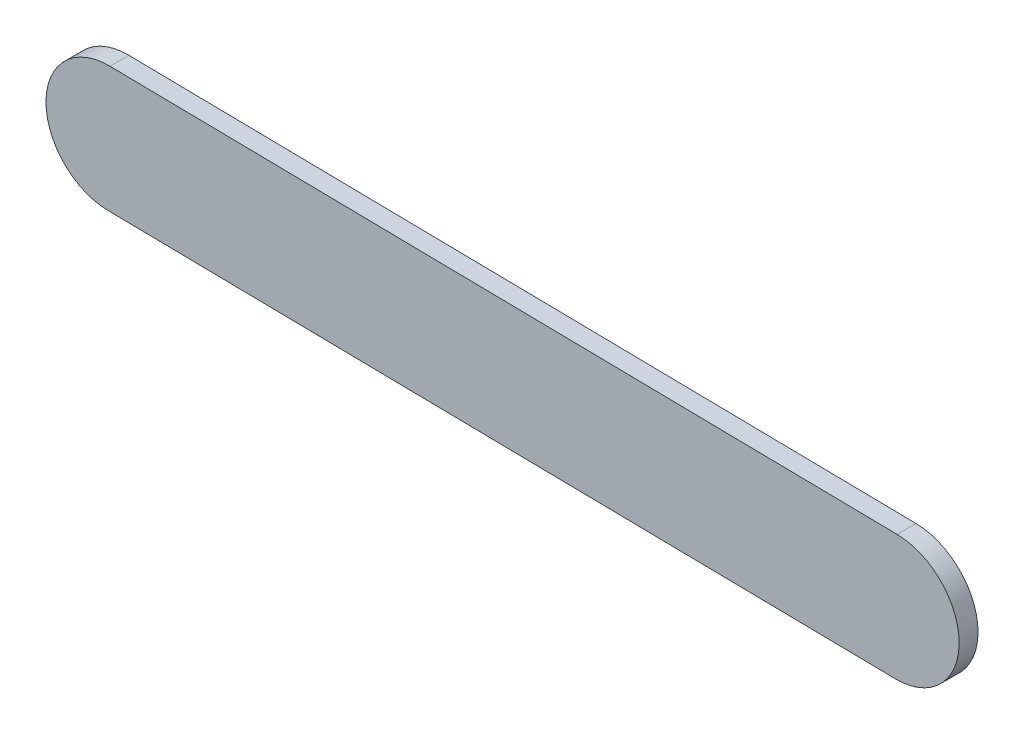
from build123d import *

# Parameters (mm, degrees)
BOSS_EXTRUDE1_DEPTH = 6
SKETCH2_R           = 12.2
BOSS_EXTRUDE2_DEPTH = 5.25


with BuildPart() as part:
    # Sketch1 → Boss-Extrude1 (new body)
    with BuildSketch(Plane.XY):
        with BuildLine():
            Line((53.452478751, 19.630204959), (303.423888155, 15.84917852))
            ThreePointArc((303.423888155, 15.84917852), (323.119118527, -4.451016075), (302.818923933, -24.146246447))
            Line((302.818923933, -24.146246447), (52.847514529, -20.365220008))
            ThreePointArc((52.847514529, -20.365220008), (33.152284157, -0.065025413), (53.452478751, 19.630204959))
        make_face()
    extrude(amount=BOSS_EXTRUDE1_DEPTH)

    # Sketch2 → Boss-Extrude2 (add)
    with BuildSketch(Plane(origin=(0, 0, 0), x_dir=(-1, 0, 0), z_dir=(0, 0, -1))):
        with Locations((-53.14999664, -0.367507524)):
            Circle(SKETCH2_R)
    extrude(amount=BOSS_EXTRUDE2_DEPTH)


solid = part.part
